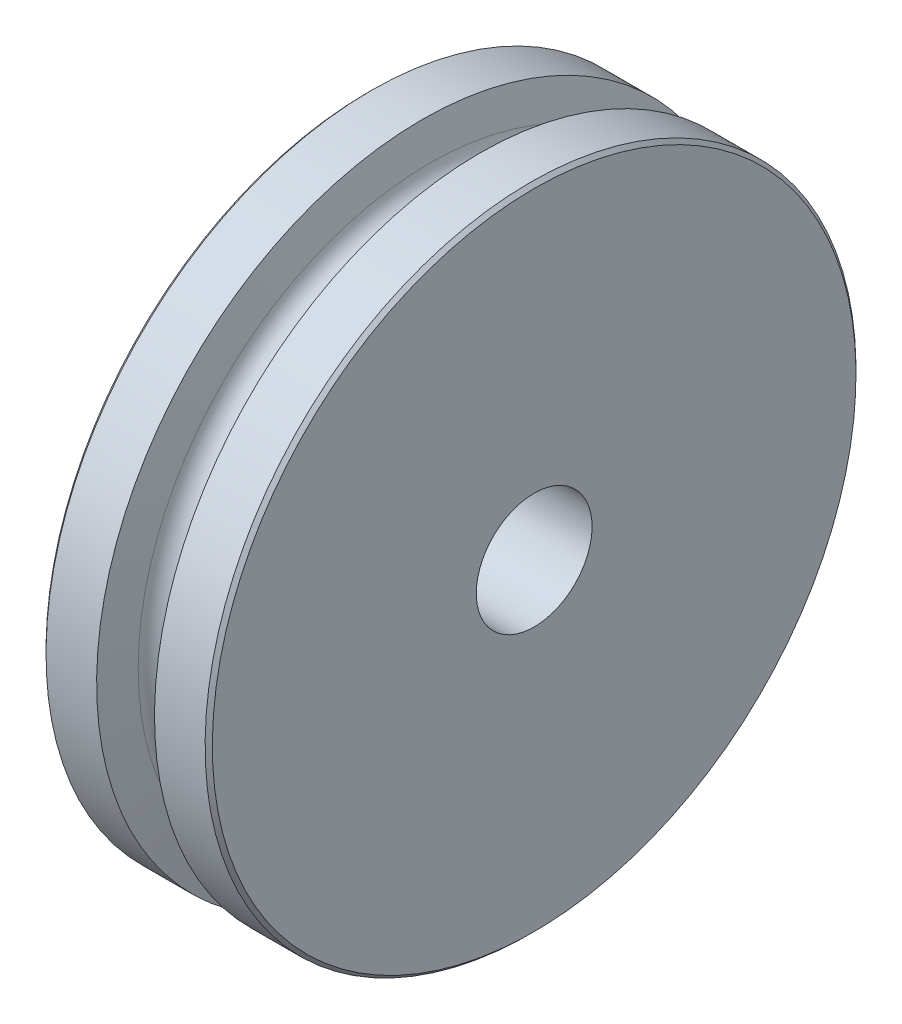
from build123d import *

# Parameters (mm, degrees)
SKETCH2_R          = 12.7127
CUT_EXTRUDE1_DEPTH = 37.5125


with BuildPart() as part:
    # Sketch1 → Revolve1 (revolve)
    with BuildSketch(Plane.XY):
        with BuildLine():
            Line((18.25625, 0), (-18.25625, 0))
            Line((-18.25625, 0), (-18.25625, 70.6374))
            Line((-18.25625, 70.6374), (-17.4625, 71.43115))
            Line((-17.4625, 71.43115), (-6.35, 71.43115))
            Line((-6.35, 71.43115), (-4.640755559, 64.017549491))
            ThreePointArc((-4.640755559, 64.017549491), (0, 60.325), (4.640755559, 64.017549491))
            Line((4.640755559, 64.017549491), (6.35, 71.43115))
            Line((6.35, 71.43115), (17.4625, 71.43115))
            Line((17.4625, 71.43115), (18.25625, 70.6374))
            Line((18.25625, 70.6374), (18.25625, 0))
        make_face()
    revolve(axis=Axis((18.25625, 0, 0), (-1, 0, 0)))

    # Sketch2 → Cut-Extrude1 (cut, through all)
    with BuildSketch(Plane(origin=(18.25625, 0, 0), x_dir=(0, 0, -1), z_dir=(1, 0, 0))):
        with Locations(Location((0, 0, 0), (0, 0, 90))):  # turned: the seam where the file's is
            Circle(SKETCH2_R)
    extrude(amount=-CUT_EXTRUDE1_DEPTH, mode=Mode.SUBTRACT)


solid = part.part
